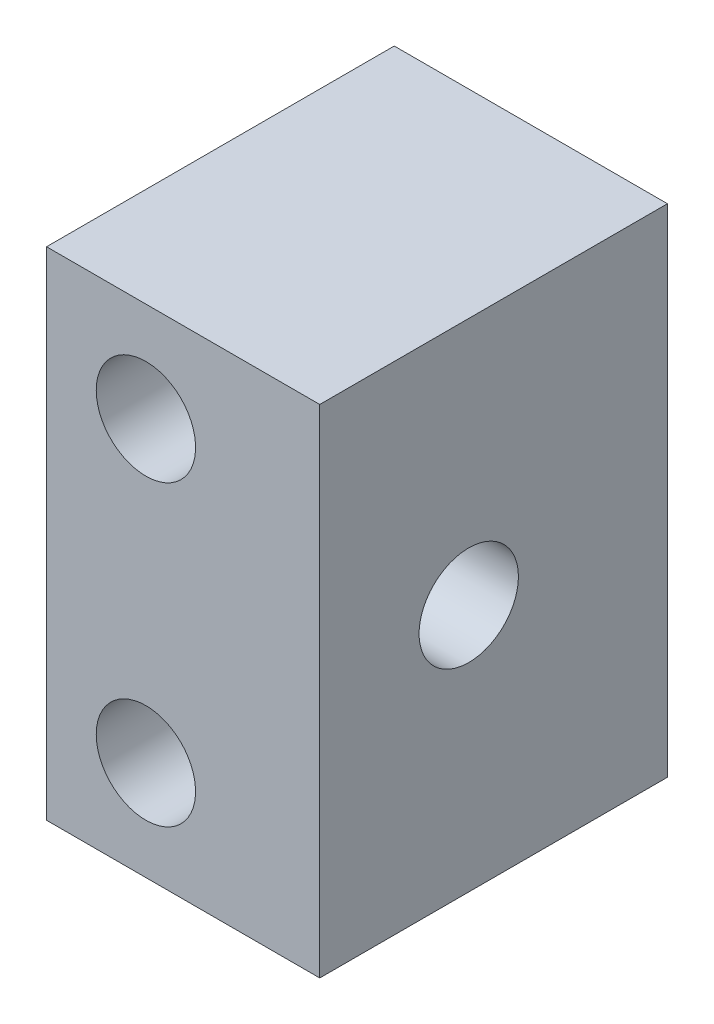
from build123d import *

# Parameters (mm, degrees)
MODEL_R                  = 1
EXTRUDE_1_DEPTH          = 4
SKETCH_1_R               = 1
CUT_EXTRUDE_1_DEPTH      = 5
CUT_EXTRUDE_1_DEPTH_BACK = 3
SKETCH_2_R               = 1.9
CUT_EXTRUDE_2_DEPTH      = 3.5
SKETCH_4_W               = 5.5
SKETCH_4_H               = 10
EXTRUDE_2_DEPTH          = 2
SKETCH_5_R               = 1
CUT_EXTRUDE_3_DEPTH      = 2
SKETCH_6_R               = 1
CUT_EXTRUDE_4_DEPTH      = 2
SKETCH_7_W               = 5.5
SKETCH_7_H               = 10
EXTRUDE_3_DEPTH          = 1
SKETCH_8_R               = 1
CUT_EXTRUDE_5_DEPTH      = 1


with BuildPart() as part:
    # Model → 凸台-拉伸1 (new body)
    with BuildSketch(Plane.XY):
        Polygon((199.499322294, 238.665580803), (199.499322294, 228.665580803), (193.999322294, 228.665580803), (193.999322294, 232.665580803), (193.999322294, 234.665580803), (193.999322294, 238.665580803), align=None)
        with Locations((195.999322294, 236.665580803)):
            Circle(MODEL_R, mode=Mode.SUBTRACT)
        with Locations((195.999322294, 230.665580803)):
            Circle(MODEL_R, mode=Mode.SUBTRACT)
        Polygon((195.999322294, 234.665580803), (197.499322294, 234.665580803), (197.499322294, 232.665580803), (195.999322294, 232.665580803), (194.999322294, 232.665580803), (194.999322294, 234.665580803), align=None, mode=Mode.SUBTRACT)
    extrude(amount=EXTRUDE_1_DEPTH)

    # 草图1 → 切除-拉伸1 (cut, two sides)
    with BuildSketch(Plane.ZY.offset(-197.499322294)) as cut_extrude_1_sk:
        with Locations((2, 233.665580803)):
            Circle(SKETCH_1_R)
    extrude(amount=CUT_EXTRUDE_1_DEPTH, mode=Mode.SUBTRACT)
    extrude(cut_extrude_1_sk.sketch, amount=-CUT_EXTRUDE_1_DEPTH_BACK, mode=Mode.SUBTRACT)

    # 草图2 → 切除-拉伸2 (cut)
    with BuildSketch(Plane.ZY.offset(-193.999322294)):
        with Locations((2, 233.665580803)):
            Circle(SKETCH_2_R)
    extrude(amount=-CUT_EXTRUDE_2_DEPTH, mode=Mode.SUBTRACT)

    # 草图4 → 凸台-拉伸2 (add)
    with BuildSketch(Plane(origin=(0, 0, 0), x_dir=(-1, 0, 0), z_dir=(0, 0, -1))):
        with Locations((-196.749322294, 233.665580803)):
            Rectangle(SKETCH_4_W, SKETCH_4_H)
    extrude(amount=EXTRUDE_2_DEPTH)

    # 草图5 → 切除-拉伸3 (cut)
    with BuildSketch(Plane.XY):
        with Locations((195.999322294, 236.665580803)):
            Circle(SKETCH_5_R)
    extrude(amount=-CUT_EXTRUDE_3_DEPTH, mode=Mode.SUBTRACT)

    # 草图6 → 切除-拉伸4 (cut)
    with BuildSketch(Plane.XY):
        with Locations((195.999322294, 230.665580803)):
            Circle(SKETCH_6_R)
    extrude(amount=-CUT_EXTRUDE_4_DEPTH, mode=Mode.SUBTRACT)

    # 草图7 → 凸台-拉伸3 (add)
    with BuildSketch(Plane.XY.offset(4)):
        with Locations((196.749322294, 233.665580803)):
            Rectangle(SKETCH_7_W, SKETCH_7_H)
    extrude(amount=EXTRUDE_3_DEPTH)

    # 草图8 → 切除-拉伸5 (cut)
    with BuildSketch(Plane(origin=(0, 0, 4), x_dir=(-1, 0, 0), z_dir=(0, 0, -1))):
        with Locations((-195.999322294, 236.665580803)):
            Circle(SKETCH_8_R)
        with Locations((-195.999322294, 230.665580803)):
            Circle(SKETCH_8_R)
    extrude(amount=-CUT_EXTRUDE_5_DEPTH, mode=Mode.SUBTRACT)


solid = part.part
